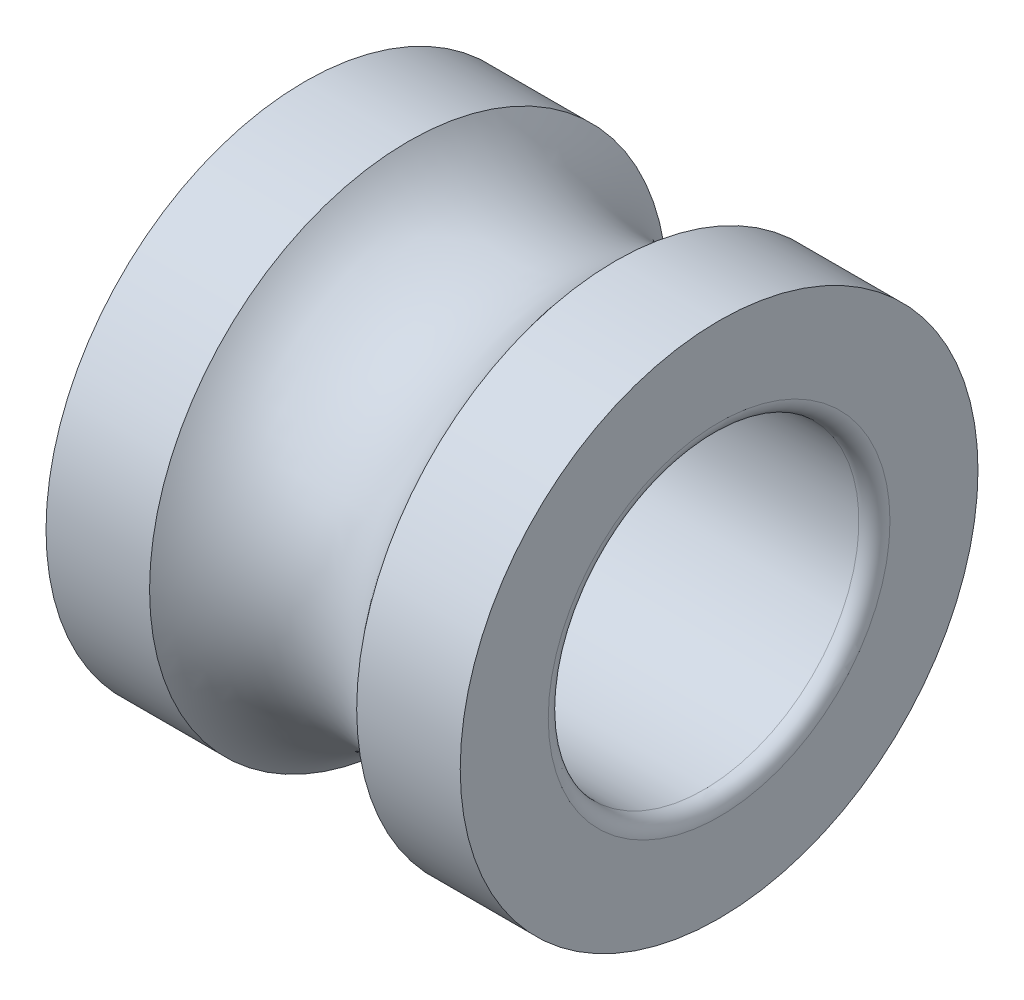
from build123d import *

# Parameters (mm, degrees)
CONG_1_R = 0.15


with BuildPart() as part:
    # Esquisse1 → Base-Révolution (revolve)
    with BuildSketch(Plane.XY):
        with BuildLine():
            Line((0, 1.5), (0, 2.5))
            Line((0, 2.5), (1, 2.5))
            ThreePointArc((1, 2.5), (2, 2), (3, 2.5))
            Line((3, 2.5), (4, 2.5))
            Line((4, 2.5), (4, 1.5))
            Line((4, 1.5), (0, 1.5))
        make_face()
    revolve(axis=Axis((0, 0, 0), (1, 0, 0)))

    # Congé1
    cong_1_edges = [part.edges().sort_by_distance(p)[0] for p in [
        (0, -1.5, 0),
        (4, -1.5, 0),
    ]]
    fillet(cong_1_edges, radius=CONG_1_R)


solid = part.part
